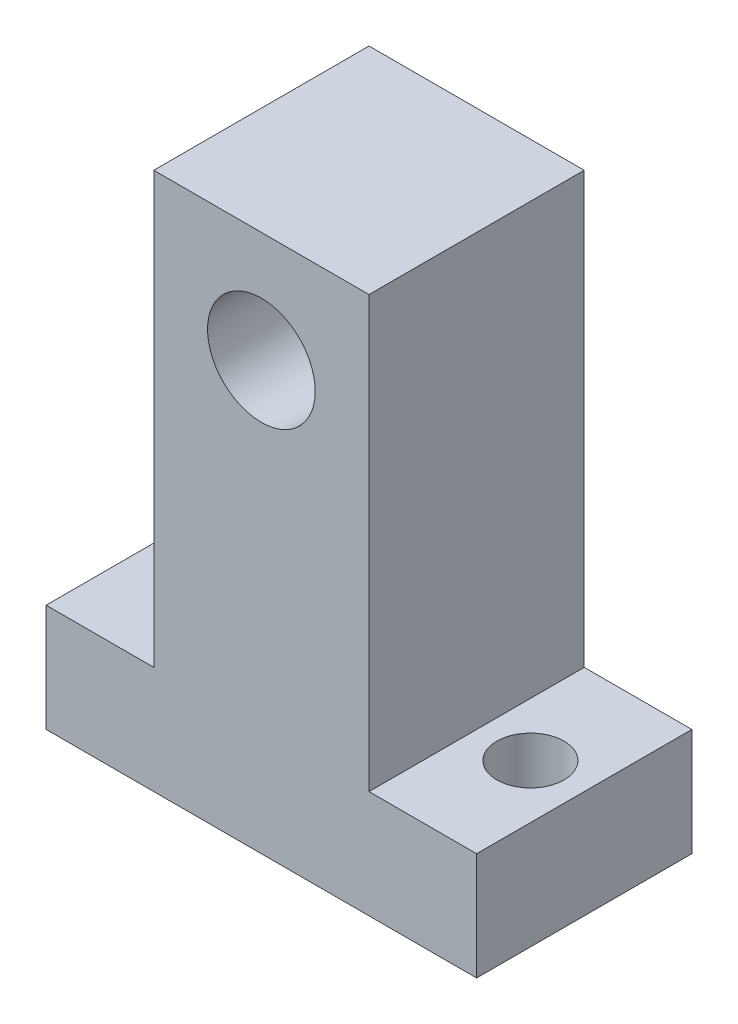
from build123d import *

# Parameters (mm, degrees)
EXTRUDE_1_DEPTH     = 16
SKETCH_2_R          = 2.5
CUT_EXTRUDE_1_DEPTH = 9
SKETCH_3_R          = 4
CUT_EXTRUDE_2_DEPTH = 29


with BuildPart() as part:
    # 草图1 → 凸台-拉伸1 (new body)
    with BuildSketch(Plane.XY):
        Polygon((0, 0), (16, 0), (16, 8), (8, 8), (8, 40), (-8, 40), (-8, 8), (-16, 8), (-16, 0), align=None)
    extrude(amount=EXTRUDE_1_DEPTH)

    # 草图2 → 切除-拉伸1 (cut, through all)
    with BuildSketch(Plane(origin=(0, 8, 0), x_dir=(1, 0, 0), z_dir=(0, 1, 0))):
        with Locations((-12, -8)):
            Circle(SKETCH_2_R)
        with Locations((12, -8)):
            Circle(SKETCH_2_R)
    extrude(amount=-CUT_EXTRUDE_1_DEPTH, mode=Mode.SUBTRACT)

    # 草图3 → 切除-拉伸2 (cut)
    with BuildSketch(Plane.XY.offset(16)):
        with Locations((0, 31.77)):
            Circle(SKETCH_3_R)
    extrude(amount=-CUT_EXTRUDE_2_DEPTH, mode=Mode.SUBTRACT)


solid = part.part
